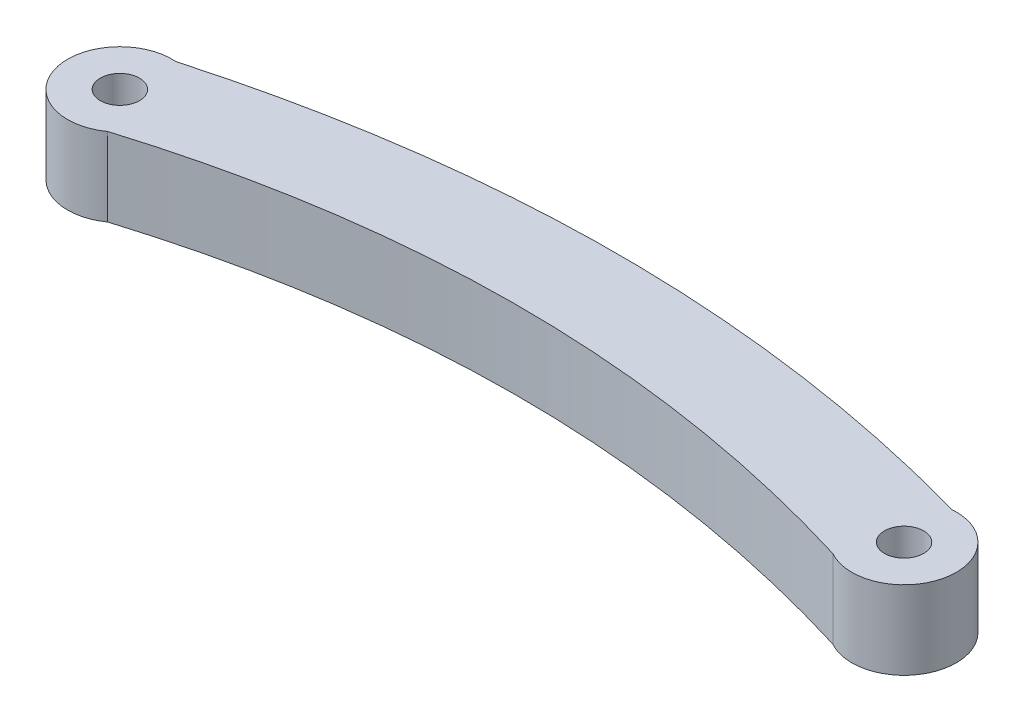
from build123d import *

# Parameters (mm, degrees)
SKETCH1_R           = 1.5
BOSS_EXTRUDE1_DEPTH = 6


with BuildPart() as part:
    # Sketch1 → Boss-Extrude1 (new body)
    with BuildSketch(Plane(origin=(0, 0, 0), x_dir=(1, 0, 0), z_dir=(0, 1, 0))):
        with BuildLine():
            ThreePointArc((-59.687638113, 12.774374027), (-63.854017455, 7.715818425), (-57.675322321, 5.531458557))
            add(Edge.make_bspline(
                [(-57.675322321, 5.531458557), (-48.450214881, 8.368212133), (-29.885063183, 11.107920581), (-11.319911486, 8.159941585), (-1.979867229, 5.310941391)],
                knots=[0.038744628, 0.038744628, 0.038744628, 0.038744628, 0.5, 0.967002213, 0.967002213, 0.967002213, 0.967002213], degree=3))
            ThreePointArc((-1.979867229, 5.310941391), (3.903752715, 7.914399297), (-0.312361887, 12.774374027))
            add(Edge.make_bspline(
                [(-59.687638113, 12.774374027), (-49.791758742, 15.54092351), (-30, 18.307472992), (-10.208241258, 15.54092351), (-0.312361887, 12.774374027)],
                knots=[0.005206031, 0.005206031, 0.005206031, 0.005206031, 0.5, 0.994793969, 0.994793969, 0.994793969, 0.994793969], degree=3))
        make_face()
        with Locations((-60, 8.786588921)):
            Circle(SKETCH1_R, mode=Mode.SUBTRACT)
        with Locations((0, 8.786588921)):
            Circle(SKETCH1_R, mode=Mode.SUBTRACT)
    extrude(amount=BOSS_EXTRUDE1_DEPTH)


solid = part.part
